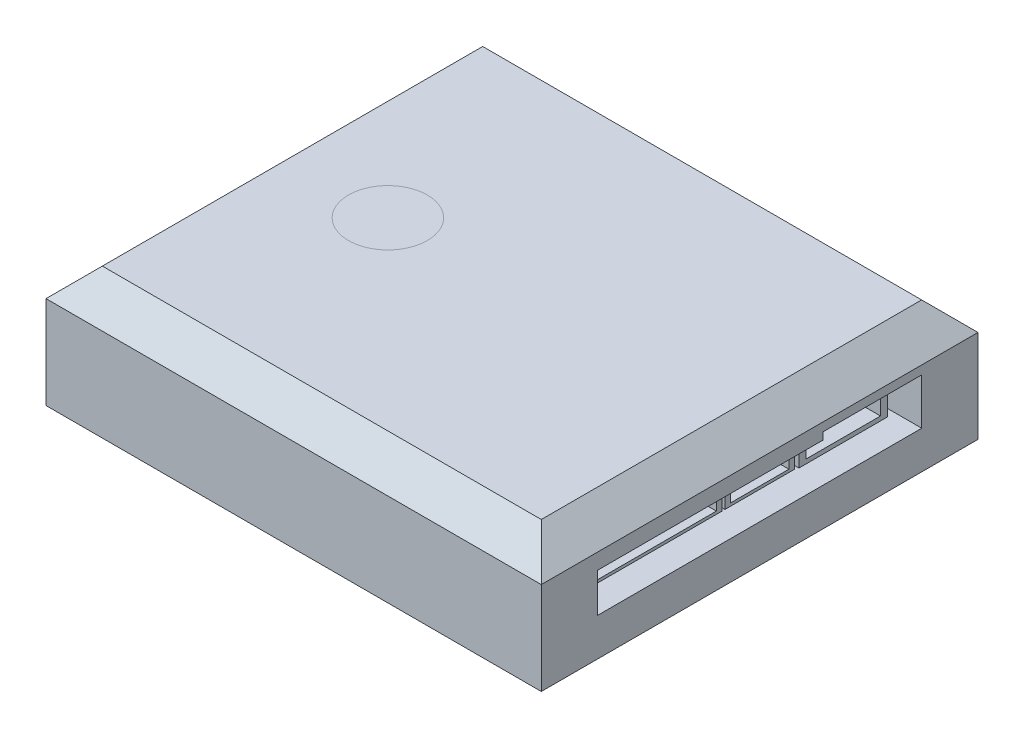
from build123d import *

# Parameters (mm, degrees)
SKETCH1_W            = 43.95
SKETCH1_H            = 38.75
BOSS_EXTRUDE1_DEPTH  = 12.4968
CHAMFER1_SIZE        = 2.5
CHAMFER2_SIZE        = 1.778
SKETCH2_W            = 28.7655
SKETCH2_H            = 3.4671
SKETCH2_W_2          = 8.763
SKETCH2_H_2          = 0.635
CUT_EXTRUDE1_DEPTH   = 6.9342
SKETCH3_W            = 12.5476
SKETCH3_H            = 3.0099
SKETCH3_W_2          = 6.1849
SKETCH3_W_3          = 7.874
SKETCH3_H_2          = 3.8481
BOSS_EXTRUDE2_DEPTH  = 4.6736
CUT_EXTRUDE3_START   = 1.27
CUT_EXTRUDE3_DEPTH   = 3.4036
SKETCH4_R            = 0.1905
SKETCH4_R_2          = 0.254
PINS_DEPTH           = 3.0226
SKETCH6_W            = 4.980118903
SKETCH6_H            = 2.927945053
SKETCH6_W_2          = 6.188094789
CUT_EXTRUDE4_DEPTH   = 7.366
BOSS_EXTRUDE6_START  = -2.286
SKETCH6_7_W          = 4.980118903
SKETCH6_7_H          = 2.927945053
SKETCH6_7_W_2        = 6.188094789
BOSS_EXTRUDE6_DEPTH  = 7.366
BOSS_EXTRUDE7_START  = -5.08
BOSS_EXTRUDE7_DEPTH  = 1.27
SKETCH7_R            = 0.1905
BOSS_EXTRUDE8_DEPTH  = 1.524
SKETCH8_W            = 27.697495277
SKETCH8_H            = 4.307026778
SKETCH8_W_2          = 8.315874778
SKETCH8_H_2          = 3.037026778
SKETCH8_W_3          = 6.16236139
SKETCH8_W_4          = 8.647259109
CUT_EXTRUDE5_DEPTH   = 7.170409787
BOSS_EXTRUDE9_START  = -2.286
SKETCH8_3_W          = 8.315874778
SKETCH8_3_H          = 3.037026778
SKETCH8_3_W_2        = 6.16236139
SKETCH8_3_W_3        = 8.647259109
BOSS_EXTRUDE9_DEPTH  = 4.884409787
BOSS_EXTRUDE10_START = -7.112
BOSS_EXTRUDE10_DEPTH = 1.27
SKETCH9_R            = 0.1905
BOSS_EXTRUDE11_DEPTH = 3.302


with BuildPart() as part:
    # Sketch1 → Boss-Extrude1 (new body)
    with BuildSketch(Plane(origin=(0, 0, 0), x_dir=(1, 0, 0), z_dir=(0, 1, 0))):
        Rectangle(SKETCH1_W, SKETCH1_H)
    extrude(amount=BOSS_EXTRUDE1_DEPTH)

    # Chamfer1
    chamfer1_edges = [part.edges().sort_by_distance(p)[0] for p in [
        (-21.975, 12.4968, 0),
        (0, 12.4968, 19.375),
        (21.975, 12.4968, 0),
        (0, 12.4968, -19.375),
    ]]
    chamfer(chamfer1_edges, length=CHAMFER1_SIZE)

    # Chamfer2
    chamfer2_edges = [part.edges().sort_by_distance(p)[0] for p in [
        (0, 0, 19.375),
        (-21.975, 0, 0),
        (0, 0, -19.375),
        (21.975, 0, 0),
    ]]
    chamfer(chamfer2_edges, length=CHAMFER2_SIZE)

    # Sketch2 → Cut-Extrude1 (cut)
    with BuildSketch(Plane(origin=(21.975, 0, 0), x_dir=(0, 0, -1), z_dir=(1, 0, 0))):
        with Locations((0, 6.86625)):
            Rectangle(SKETCH2_W, SKETCH2_H)
        with Locations((10.00125, 8.9173)):
            Rectangle(SKETCH2_W_2, SKETCH2_H_2)
    extrude(amount=-CUT_EXTRUDE1_DEPTH, mode=Mode.SUBTRACT)

    # Sketch3 → Boss-Extrude2 (add)
    with BuildSketch(Plane(origin=(15.0408, 0, 0), x_dir=(0, 0, -1), z_dir=(1, 0, 0))):
        with Locations((-7.34695, 6.86625)):
            Rectangle(SKETCH3_W, SKETCH3_H)
        Polygon((-13.11275, 7.1012), (-13.11275, 5.6153), (-1.58115, 5.6153), (-1.58115, 7.1012), (-1.32715, 7.1012), (-1.32715, 7.6092), (-1.58115, 7.6092), (-1.58115, 8.1172), (-13.11275, 8.1172), (-13.11275, 7.6092), (-13.36675, 7.6092), (-13.36675, 7.1012), align=None, mode=Mode.SUBTRACT)
        Polygon((-13.11275, 7.1012), (-13.36675, 7.1012), (-13.36675, 7.6092), (-13.11275, 7.6092), (-13.11275, 8.1172), (-1.58115, 8.1172), (-1.58115, 7.6092), (-1.32715, 7.6092), (-1.32715, 7.1012), (-1.58115, 7.1012), (-1.58115, 5.6153), (-13.11275, 5.6153), align=None)
        with Locations((2.2733, 6.86625)):
            Rectangle(SKETCH3_W_2, SKETCH3_H)
        Polygon((-0.31115, 7.1012), (-0.31115, 5.6153), (4.85775, 5.6153), (4.85775, 7.1012), (5.11175, 7.1012), (5.11175, 7.6092), (4.85775, 7.6092), (4.85775, 8.1172), (-0.31115, 8.1172), (-0.31115, 7.6092), (-0.56515, 7.6092), (-0.56515, 7.1012), align=None, mode=Mode.SUBTRACT)
        Polygon((-0.31115, 7.1012), (-0.56515, 7.1012), (-0.56515, 7.6092), (-0.31115, 7.6092), (-0.31115, 8.1172), (4.85775, 8.1172), (4.85775, 7.6092), (5.11175, 7.6092), (5.11175, 7.1012), (4.85775, 7.1012), (4.85775, 5.6153), (-0.31115, 5.6153), align=None)
        with Locations((9.68375, 7.18375)):
            Rectangle(SKETCH3_W_3, SKETCH3_H_2)
        Polygon((6.38175, 7.4568), (6.38175, 5.6407), (12.98575, 5.6407), (12.98575, 7.4568), (13.36675, 7.4568), (13.36675, 8.2188), (12.98575, 8.2188), (12.98575, 8.7268), (6.38175, 8.7268), (6.38175, 8.2188), (6.00075, 8.2188), (6.00075, 7.4568), align=None, mode=Mode.SUBTRACT)
        Polygon((6.38175, 7.4568), (6.00075, 7.4568), (6.00075, 8.2188), (6.38175, 8.2188), (6.38175, 8.7268), (12.98575, 8.7268), (12.98575, 8.2188), (13.36675, 8.2188), (13.36675, 7.4568), (12.98575, 7.4568), (12.98575, 5.6407), (6.38175, 5.6407), align=None)
    extrude(amount=BOSS_EXTRUDE2_DEPTH)

    # Sketch3_4 → Cut-Extrude3 (cut)
    with BuildSketch(Plane(origin=(15.0408, 0, 0), x_dir=(0, 0, -1), z_dir=(1, 0, 0)).offset(CUT_EXTRUDE3_START)):
        Polygon((-13.11275, 7.1012), (-13.36675, 7.1012), (-13.36675, 7.6092), (-13.11275, 7.6092), (-13.11275, 8.1172), (-1.58115, 8.1172), (-1.58115, 7.6092), (-1.32715, 7.6092), (-1.32715, 7.1012), (-1.58115, 7.1012), (-1.58115, 5.6153), (-13.11275, 5.6153), align=None)
        Polygon((-0.31115, 7.1012), (-0.56515, 7.1012), (-0.56515, 7.6092), (-0.31115, 7.6092), (-0.31115, 8.1172), (4.85775, 8.1172), (4.85775, 7.6092), (5.11175, 7.6092), (5.11175, 7.1012), (4.85775, 7.1012), (4.85775, 5.6153), (-0.31115, 5.6153), align=None)
        Polygon((6.38175, 7.4568), (6.00075, 7.4568), (6.00075, 8.2188), (6.38175, 8.2188), (6.38175, 8.7268), (12.98575, 8.7268), (12.98575, 8.2188), (13.36675, 8.2188), (13.36675, 7.4568), (12.98575, 7.4568), (12.98575, 5.6407), (6.38175, 5.6407), align=None)
    extrude(amount=CUT_EXTRUDE3_DEPTH, mode=Mode.SUBTRACT)

    # Sketch4 → Pins (add)
    with BuildSketch(Plane(origin=(16.3108, 0, 0), x_dir=(0, 0, -1), z_dir=(1, 0, 0))):
        with Locations((-12.629904443, 7.3552)):
            Circle(SKETCH4_R)
        with Locations((-11.461504443, 7.3552)):
            Circle(SKETCH4_R)
        with Locations((-10.293104443, 7.3552)):
            Circle(SKETCH4_R)
        with Locations((-9.124704443, 7.3552)):
            Circle(SKETCH4_R)
        with Locations((-7.956304443, 7.3552)):
            Circle(SKETCH4_R)
        with Locations((-6.787904443, 7.3552)):
            Circle(SKETCH4_R)
        with Locations((-5.619504443, 7.3552)):
            Circle(SKETCH4_R)
        with Locations((-4.451104443, 7.3552)):
            Circle(SKETCH4_R)
        with Locations((-3.282704443, 7.3552)):
            Circle(SKETCH4_R)
        with Locations((-2.114304443, 7.3552)):
            Circle(SKETCH4_R)
        with Locations((0.343037743, 7.3552)):
            Circle(SKETCH4_R)
        with Locations((2.248037743, 7.3552)):
            Circle(SKETCH4_R)
        with Locations((4.153037743, 7.3552)):
            Circle(SKETCH4_R)
        with Locations((7.146042841, 7.8378)):
            Circle(SKETCH4_R_2)
        with Locations((9.686042841, 7.8378)):
            Circle(SKETCH4_R_2)
        with Locations((12.226042841, 7.8378)):
            Circle(SKETCH4_R_2)
    extrude(amount=PINS_DEPTH)

    # Sketch6 → Cut-Extrude4 (cut)
    with BuildSketch(Plane(origin=(0, 0, -19.375), x_dir=(-1, 0, 0), z_dir=(0, 0, -1))):
        Polygon((14.779190213, 9.292249663), (14.779190213, 5.85630461), (5.591422422, 5.85630461), (3.216238929, 5.85630461), (1.578976521, 5.85630461), (1.578976521, 9.292249663), align=None)
        with Locations((4.577035973, 7.574277137)):
            Rectangle(SKETCH6_W, SKETCH6_H, mode=Mode.SUBTRACT)
        with Locations((10.923142819, 7.574277137)):
            Rectangle(SKETCH6_W_2, SKETCH6_H, mode=Mode.SUBTRACT)
        with Locations((4.577035973, 7.574277137)):
            Rectangle(SKETCH6_W, SKETCH6_H)
        Polygon((6.559095424, 7.785668245), (6.813095424, 7.785668245), (6.813095424, 8.293668245), (6.559095424, 8.293668245), (6.559095424, 8.784249663), (2.594976521, 8.784249663), (2.594976521, 8.293668245), (2.340976521, 8.293668245), (2.340976521, 7.785668245), (2.594976521, 7.785668245), (2.594976521, 6.36430461), (6.559095424, 6.36430461), align=None, mode=Mode.SUBTRACT)
        Polygon((6.559095424, 7.785668245), (6.559095424, 6.36430461), (2.594976521, 6.36430461), (2.594976521, 7.785668245), (2.340976521, 7.785668245), (2.340976521, 8.293668245), (2.594976521, 8.293668245), (2.594976521, 8.784249663), (6.559095424, 8.784249663), (6.559095424, 8.293668245), (6.813095424, 8.293668245), (6.813095424, 7.785668245), align=None)
        with Locations((10.923142819, 7.574277137)):
            Rectangle(SKETCH6_W_2, SKETCH6_H)
        Polygon((13.509190213, 7.785668245), (13.763190213, 7.785668245), (13.763190213, 8.293668245), (13.509190213, 8.293668245), (13.509190213, 8.784249663), (8.337095424, 8.784249663), (8.337095424, 8.293668245), (8.083095424, 8.293668245), (8.083095424, 7.785668245), (8.337095424, 7.785668245), (8.337095424, 6.36430461), (13.509190213, 6.36430461), align=None, mode=Mode.SUBTRACT)
        Polygon((13.509190213, 7.785668245), (13.509190213, 6.36430461), (8.337095424, 6.36430461), (8.337095424, 7.785668245), (8.083095424, 7.785668245), (8.083095424, 8.293668245), (8.337095424, 8.293668245), (8.337095424, 8.784249663), (13.509190213, 8.784249663), (13.509190213, 8.293668245), (13.763190213, 8.293668245), (13.763190213, 7.785668245), align=None)
    extrude(amount=-CUT_EXTRUDE4_DEPTH, mode=Mode.SUBTRACT)

    # Sketch6_7 → Boss-Extrude6 (add)
    with BuildSketch(Plane(origin=(0, 0, -19.375), x_dir=(-1, 0, 0), z_dir=(0, 0, -1)).offset(BOSS_EXTRUDE6_START)):
        with Locations((4.577035973, 7.574277137)):
            Rectangle(SKETCH6_7_W, SKETCH6_7_H)
        Polygon((6.559095424, 7.785668245), (6.813095424, 7.785668245), (6.813095424, 8.293668245), (6.559095424, 8.293668245), (6.559095424, 8.784249663), (2.594976521, 8.784249663), (2.594976521, 8.293668245), (2.340976521, 8.293668245), (2.340976521, 7.785668245), (2.594976521, 7.785668245), (2.594976521, 6.36430461), (6.559095424, 6.36430461), align=None, mode=Mode.SUBTRACT)
        with Locations((10.923142819, 7.574277137)):
            Rectangle(SKETCH6_7_W_2, SKETCH6_7_H)
        Polygon((13.509190213, 7.785668245), (13.763190213, 7.785668245), (13.763190213, 8.293668245), (13.509190213, 8.293668245), (13.509190213, 8.784249663), (8.337095424, 8.784249663), (8.337095424, 8.293668245), (8.083095424, 8.293668245), (8.083095424, 7.785668245), (8.337095424, 7.785668245), (8.337095424, 6.36430461), (13.509190213, 6.36430461), align=None, mode=Mode.SUBTRACT)
    extrude(amount=-BOSS_EXTRUDE6_DEPTH)

    # Sketch6_8 → Boss-Extrude7 (add)
    with BuildSketch(Plane(origin=(0, 0, -19.375), x_dir=(-1, 0, 0), z_dir=(0, 0, -1)).offset(BOSS_EXTRUDE7_START)):
        Polygon((6.559095424, 7.785668245), (6.559095424, 6.36430461), (2.594976521, 6.36430461), (2.594976521, 7.785668245), (2.340976521, 7.785668245), (2.340976521, 8.293668245), (2.594976521, 8.293668245), (2.594976521, 8.784249663), (6.559095424, 8.784249663), (6.559095424, 8.293668245), (6.813095424, 8.293668245), (6.813095424, 7.785668245), align=None)
        Polygon((13.509190213, 7.785668245), (13.509190213, 6.36430461), (8.337095424, 6.36430461), (8.337095424, 7.785668245), (8.083095424, 7.785668245), (8.083095424, 8.293668245), (8.337095424, 8.293668245), (8.337095424, 8.784249663), (13.509190213, 8.784249663), (13.509190213, 8.293668245), (13.763190213, 8.293668245), (13.763190213, 7.785668245), align=None)
    extrude(amount=BOSS_EXTRUDE7_DEPTH)

    # Sketch7 → Boss-Extrude8 (add)
    with BuildSketch(Plane(origin=(0, 0, -15.565), x_dir=(-1, 0, 0), z_dir=(0, 0, -1))):
        with Locations((3.239305638, 8.039668245)):
            Circle(SKETCH7_R)
        with Locations((8.958754307, 8.039668245)):
            Circle(SKETCH7_R)
        with Locations((4.509305638, 8.039668245)):
            Circle(SKETCH7_R)
        with Locations((5.779305638, 8.039668245)):
            Circle(SKETCH7_R)
        with Locations((10.228754307, 8.039668245)):
            Circle(SKETCH7_R)
        with Locations((11.498754307, 8.039668245)):
            Circle(SKETCH7_R)
        with Locations((12.768754307, 8.039668245)):
            Circle(SKETCH7_R)
    extrude(amount=BOSS_EXTRUDE8_DEPTH)

    # Sketch8 → Cut-Extrude5 (cut)
    with BuildSketch(Plane.ZY.offset(21.975)):
        with Locations((0.025099221, 7.299711756)):
            Rectangle(SKETCH8_W, SKETCH8_H)
        with Locations((-8.903711028, 7.172711756)):
            Rectangle(SKETCH8_W_2, SKETCH8_H_2, mode=Mode.SUBTRACT)
        with Locations((-0.140592944, 7.172711756)):
            Rectangle(SKETCH8_W_3, SKETCH8_H_2, mode=Mode.SUBTRACT)
        with Locations((8.788217305, 7.172711756)):
            Rectangle(SKETCH8_W_4, SKETCH8_H_2, mode=Mode.SUBTRACT)
        with Locations((-8.903711028, 7.172711756)):
            Rectangle(SKETCH8_W_2, SKETCH8_H_2)
        Polygon((-12.553648417, 7.433678621), (-12.553648417, 5.908198367), (-5.253773639, 5.908198367), (-5.253773639, 7.433678621), (-4.999773639, 7.433678621), (-4.999773639, 7.941678621), (-5.253773639, 7.941678621), (-5.253773639, 8.437225145), (-12.553648417, 8.437225145), (-12.553648417, 7.941678621), (-12.807648417, 7.941678621), (-12.807648417, 7.433678621), align=None, mode=Mode.SUBTRACT)
        Polygon((-12.553648417, 7.433678621), (-12.807648417, 7.433678621), (-12.807648417, 7.941678621), (-12.553648417, 7.941678621), (-12.553648417, 8.437225145), (-5.253773639, 8.437225145), (-5.253773639, 7.941678621), (-4.999773639, 7.941678621), (-4.999773639, 7.433678621), (-5.253773639, 7.433678621), (-5.253773639, 5.908198367), (-12.553648417, 5.908198367), align=None)
        with Locations((-0.140592944, 7.172711756)):
            Rectangle(SKETCH8_W_3, SKETCH8_H_2)
        Polygon((2.432587751, 8.437225145), (2.432587751, 7.941678621), (2.686587751, 7.941678621), (2.686587751, 7.433678621), (2.432587751, 7.433678621), (2.432587751, 5.908198367), (-2.713773639, 5.908198367), (-2.713773639, 7.433678621), (-2.967773639, 7.433678621), (-2.967773639, 7.941678621), (-2.713773639, 7.941678621), (-2.713773639, 8.437225145), align=None, mode=Mode.SUBTRACT)
        Polygon((2.432587751, 7.941678621), (2.686587751, 7.941678621), (2.686587751, 7.433678621), (2.432587751, 7.433678621), (2.432587751, 5.908198367), (-2.713773639, 5.908198367), (-2.713773639, 7.433678621), (-2.967773639, 7.433678621), (-2.967773639, 7.941678621), (-2.713773639, 7.941678621), (-2.713773639, 8.437225145), (2.432587751, 8.437225145), align=None)
        with Locations((8.788217305, 7.172711756)):
            Rectangle(SKETCH8_W_4, SKETCH8_H_2)
        Polygon((12.60384686, 7.433678621), (12.85784686, 7.433678621), (12.85784686, 7.941678621), (12.60384686, 7.941678621), (12.60384686, 8.437225145), (4.972587751, 8.437225145), (4.972587751, 7.941678621), (4.718587751, 7.941678621), (4.718587751, 7.433678621), (4.972587751, 7.433678621), (4.972587751, 5.908198367), (12.60384686, 5.908198367), align=None, mode=Mode.SUBTRACT)
        Polygon((12.60384686, 7.433678621), (12.60384686, 5.908198367), (4.972587751, 5.908198367), (4.972587751, 7.433678621), (4.718587751, 7.433678621), (4.718587751, 7.941678621), (4.972587751, 7.941678621), (4.972587751, 8.437225145), (12.60384686, 8.437225145), (12.60384686, 7.941678621), (12.85784686, 7.941678621), (12.85784686, 7.433678621), align=None)
    extrude(amount=-CUT_EXTRUDE5_DEPTH, mode=Mode.SUBTRACT)

    # Sketch8_3 → Boss-Extrude9 (add)
    with BuildSketch(Plane.ZY.offset(21.975).offset(BOSS_EXTRUDE9_START)):
        with Locations((-8.903711028, 7.172711756)):
            Rectangle(SKETCH8_3_W, SKETCH8_3_H)
        Polygon((-12.553648417, 7.433678621), (-12.553648417, 5.908198367), (-5.253773639, 5.908198367), (-5.253773639, 7.433678621), (-4.999773639, 7.433678621), (-4.999773639, 7.941678621), (-5.253773639, 7.941678621), (-5.253773639, 8.437225145), (-12.553648417, 8.437225145), (-12.553648417, 7.941678621), (-12.807648417, 7.941678621), (-12.807648417, 7.433678621), align=None, mode=Mode.SUBTRACT)
        with Locations((-0.140592944, 7.172711756)):
            Rectangle(SKETCH8_3_W_2, SKETCH8_3_H)
        Polygon((2.432587751, 8.437225145), (2.432587751, 7.941678621), (2.686587751, 7.941678621), (2.686587751, 7.433678621), (2.432587751, 7.433678621), (2.432587751, 5.908198367), (-2.713773639, 5.908198367), (-2.713773639, 7.433678621), (-2.967773639, 7.433678621), (-2.967773639, 7.941678621), (-2.713773639, 7.941678621), (-2.713773639, 8.437225145), align=None, mode=Mode.SUBTRACT)
        with Locations((8.788217305, 7.172711756)):
            Rectangle(SKETCH8_3_W_3, SKETCH8_3_H)
        Polygon((12.60384686, 7.433678621), (12.85784686, 7.433678621), (12.85784686, 7.941678621), (12.60384686, 7.941678621), (12.60384686, 8.437225145), (4.972587751, 8.437225145), (4.972587751, 7.941678621), (4.718587751, 7.941678621), (4.718587751, 7.433678621), (4.972587751, 7.433678621), (4.972587751, 5.908198367), (12.60384686, 5.908198367), align=None, mode=Mode.SUBTRACT)
    extrude(amount=-BOSS_EXTRUDE9_DEPTH)

    # Sketch8_5 → Boss-Extrude10 (add)
    with BuildSketch(Plane.ZY.offset(21.975).offset(BOSS_EXTRUDE10_START)):
        Polygon((-12.553648417, 7.433678621), (-12.807648417, 7.433678621), (-12.807648417, 7.941678621), (-12.553648417, 7.941678621), (-12.553648417, 8.437225145), (-5.253773639, 8.437225145), (-5.253773639, 7.941678621), (-4.999773639, 7.941678621), (-4.999773639, 7.433678621), (-5.253773639, 7.433678621), (-5.253773639, 5.908198367), (-12.553648417, 5.908198367), align=None)
        Polygon((2.432587751, 7.941678621), (2.686587751, 7.941678621), (2.686587751, 7.433678621), (2.432587751, 7.433678621), (2.432587751, 5.908198367), (-2.713773639, 5.908198367), (-2.713773639, 7.433678621), (-2.967773639, 7.433678621), (-2.967773639, 7.941678621), (-2.713773639, 7.941678621), (-2.713773639, 8.437225145), (2.432587751, 8.437225145), align=None)
        Polygon((12.60384686, 7.433678621), (12.60384686, 5.908198367), (4.972587751, 5.908198367), (4.972587751, 7.433678621), (4.718587751, 7.433678621), (4.718587751, 7.941678621), (4.972587751, 7.941678621), (4.972587751, 8.437225145), (12.60384686, 8.437225145), (12.60384686, 7.941678621), (12.85784686, 7.941678621), (12.85784686, 7.433678621), align=None)
    extrude(amount=BOSS_EXTRUDE10_DEPTH)

    # Sketch9 → Boss-Extrude11 (add)
    with BuildSketch(Plane.ZY.offset(16.133)):
        with Locations((-12.099676614, 7.687678621)):
            Circle(SKETCH9_R)
        with Locations((-2.083361744, 7.687678621)):
            Circle(SKETCH9_R)
        with Locations((5.582986841, 7.687678621)):
            Circle(SKETCH9_R)
        with Locations((-10.829676614, 7.687678621)):
            Circle(SKETCH9_R)
        with Locations((-9.559676614, 7.687678621)):
            Circle(SKETCH9_R)
        with Locations((-8.289676614, 7.687678621)):
            Circle(SKETCH9_R)
        with Locations((-7.019676614, 7.687678621)):
            Circle(SKETCH9_R)
        with Locations((-5.749676614, 7.687678621)):
            Circle(SKETCH9_R)
        with Locations((6.852986841, 7.687678621)):
            Circle(SKETCH9_R)
        with Locations((8.122986841, 7.687678621)):
            Circle(SKETCH9_R)
        with Locations((9.392986841, 7.687678621)):
            Circle(SKETCH9_R)
        with Locations((10.662986841, 7.687678621)):
            Circle(SKETCH9_R)
        with Locations((11.932986841, 7.687678621)):
            Circle(SKETCH9_R)
        with Locations((-0.813361744, 7.687678621)):
            Circle(SKETCH9_R)
        with Locations((0.456638256, 7.687678621)):
            Circle(SKETCH9_R)
        with Locations((1.726638256, 7.687678621)):
            Circle(SKETCH9_R)
    extrude(amount=BOSS_EXTRUDE11_DEPTH)


solid = part.part
